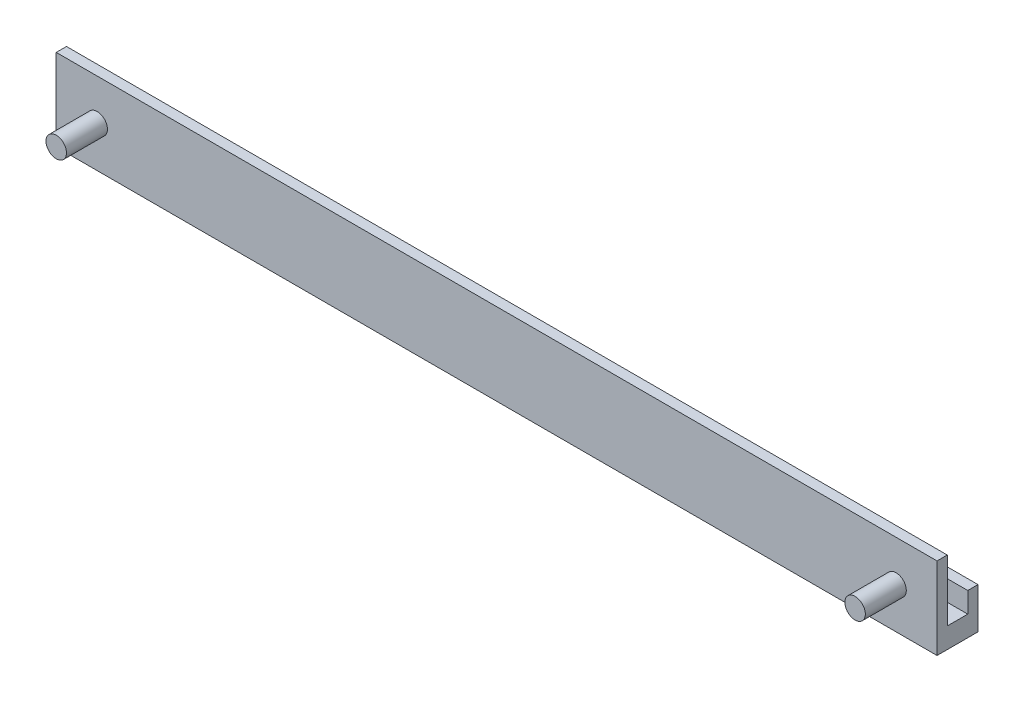
from build123d import *

# Parameters (mm, degrees)
SKETCH1_W           = 215
SKETCH1_H           = 10
BOSS_EXTRUDE1_DEPTH = 5
SKETCH4_W           = 215
SKETCH4_H           = 2.5
BOSS_EXTRUDE7_DEPTH = 15
SKETCH6_W           = 215
SKETCH6_H           = 2.5
BOSS_EXTRUDE8_DEPTH = 5
SKETCH7_R           = 2.5
BOSS_EXTRUDE9_DEPTH = 10


with BuildPart() as part:
    # Sketch1 → Boss-Extrude1 (new body)
    with BuildSketch(Plane(origin=(0, 0, 0), x_dir=(1, 0, 0), z_dir=(0, 1, 0))):
        Rectangle(SKETCH1_W, SKETCH1_H)
    extrude(amount=BOSS_EXTRUDE1_DEPTH)

    # Sketch4 → Boss-Extrude7 (add)
    with BuildSketch(Plane(origin=(0, 5, 0), x_dir=(1, 0, 0), z_dir=(0, 1, 0))):
        with Locations((0, -3.75)):
            Rectangle(SKETCH4_W, SKETCH4_H)
    extrude(amount=BOSS_EXTRUDE7_DEPTH)

    # Sketch6 → Boss-Extrude8 (add)
    with BuildSketch(Plane(origin=(0, 5, 0), x_dir=(1, 0, 0), z_dir=(0, 1, 0))):
        with Locations((0, 3.75)):
            Rectangle(SKETCH6_W, SKETCH6_H)
    extrude(amount=BOSS_EXTRUDE8_DEPTH)

    # Sketch7 → Boss-Extrude9 (add)
    with BuildSketch(Plane.XY.offset(5)):
        with Locations((-97.5, 10)):
            Circle(SKETCH7_R)
        with Locations((97.5, 10)):
            Circle(SKETCH7_R)
    extrude(amount=BOSS_EXTRUDE9_DEPTH)


solid = part.part
